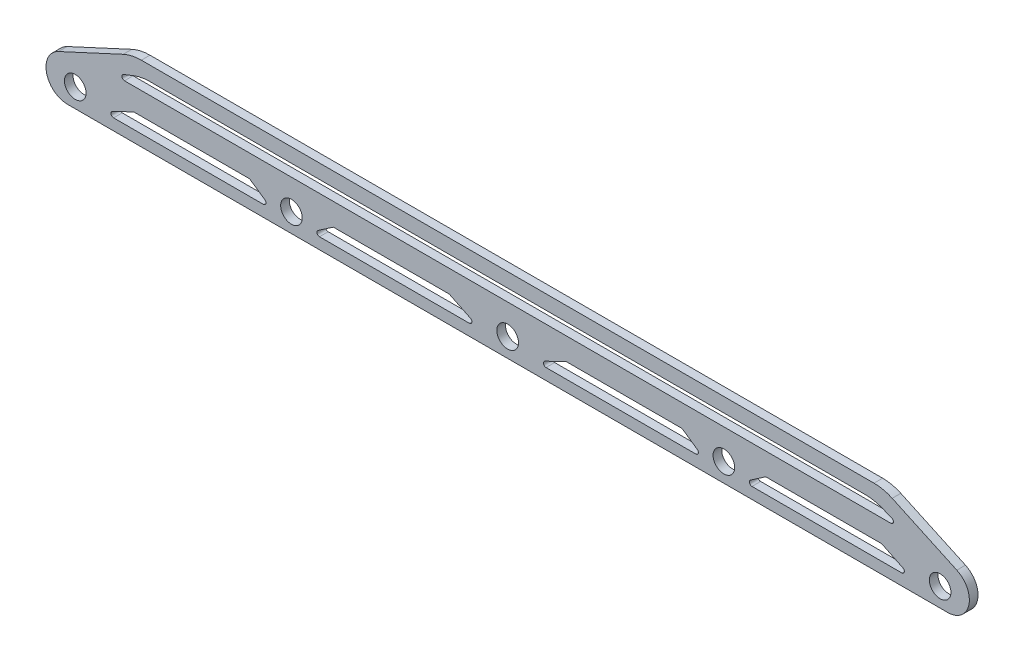
from build123d import *

# Parameters (mm, degrees)
SKETCH1_R           = 2.5
SKETCH1_R_2         = 2.506016037
BOSS_EXTRUDE1_DEPTH = 2


with BuildPart() as part:
    # Sketch1 → Boss-Extrude1 (new body)
    with BuildSketch(Plane.XY):
        with BuildLine():
            Line((84.714565194, 13), (-84.714565194, 13))
            ThreePointArc((-84.714565194, 13), (-86.865323204, 12.765973581), (-88.915414375, 12.074847997))
            Line((-88.915414375, 12.074847997), (-103.401698361, 5.368984247))
            Line((-103.401698361, 5.368984247), (-103.860380263, 5.156655237))
            ThreePointArc((-103.860380263, 5.156655237), (-106.642942464, -0.456147767), (-101.759955673, -4.380768762))
            Line((-101.759955673, -4.380768762), (101.759955673, -4.380768762))
            ThreePointArc((101.759955673, -4.380768762), (106.642942464, -0.456147767), (103.860380263, 5.156655237))
            Line((103.860380263, 5.156655237), (88.915414375, 12.074847997))
            ThreePointArc((88.915414375, 12.074847997), (86.865323204, 12.765973581), (84.714565194, 13))
        make_face()
        with Locations((-100, 0)):
            Circle(SKETCH1_R, mode=Mode.SUBTRACT)
        with BuildLine():
            Line((-59.681677735, 1.761321711), (-56.14514104, -0.666672148))
            ThreePointArc((-56.14514104, -0.666672148), (-55.911681313, -1.339099386), (-56.484737706, -1.761317581))
            Line((-56.484737706, -1.761317581), (-91.130638371, -1.761317581))
            ThreePointArc((-91.130638371, -1.761317581), (-91.71541475, -1.295617942), (-91.392423967, -0.621439537))
            Line((-91.392423967, -0.621439537), (-86.478477199, 1.761321711))
            Line((-86.478477199, 1.761321711), (-59.681677735, 1.761321711))
        make_face(mode=Mode.SUBTRACT)
        with Locations((-50, 0)):
            Circle(SKETCH1_R, mode=Mode.SUBTRACT)
        with BuildLine():
            Line((-13.521523964, 1.761321711), (-8.607577196, -0.621439537))
            ThreePointArc((-8.607577196, -0.621439537), (-8.284586412, -1.295617942), (-8.869362791, -1.761317581))
            Line((-8.869362791, -1.761317581), (-43.515263456, -1.761317581))
            ThreePointArc((-43.515263456, -1.761317581), (-44.08831985, -1.339099386), (-43.854860123, -0.666672148))
            Line((-43.854860123, -0.666672148), (-40.318323427, 1.761321711))
            Line((-40.318323427, 1.761321711), (-13.521523964, 1.761321711))
        make_face(mode=Mode.SUBTRACT)
        Circle(SKETCH1_R_2, mode=Mode.SUBTRACT)
        with BuildLine():
            Line((40.318323427, 1.761321711), (43.854860123, -0.666672148))
            ThreePointArc((43.854860123, -0.666672148), (44.08831985, -1.339099386), (43.515263456, -1.761317581))
            Line((43.515263456, -1.761317581), (8.869362791, -1.761317581))
            ThreePointArc((8.869362791, -1.761317581), (8.284586412, -1.295617942), (8.607577196, -0.621439537))
            Line((8.607577196, -0.621439537), (13.521523964, 1.761321711))
            Line((13.521523964, 1.761321711), (40.318323427, 1.761321711))
        make_face(mode=Mode.SUBTRACT)
        with Locations((50.000000581, 2.065e-06)):
            Circle(SKETCH1_R, mode=Mode.SUBTRACT)
        with BuildLine():
            Line((86.478477199, 1.761321711), (91.392423967, -0.621439537))
            ThreePointArc((91.392423967, -0.621439537), (91.71541475, -1.295617942), (91.130638371, -1.761317581))
            Line((91.130638371, -1.761317581), (56.484737706, -1.761317581))
            ThreePointArc((56.484737706, -1.761317581), (55.911681313, -1.339099386), (56.14514104, -0.666672148))
            Line((56.14514104, -0.666672148), (59.681677735, 1.761321711))
            Line((59.681677735, 1.761321711), (86.478477199, 1.761321711))
        make_face(mode=Mode.SUBTRACT)
        with Locations((100, 0)):
            Circle(SKETCH1_R, mode=Mode.SUBTRACT)
        with BuildLine():
            ThreePointArc((-86.478477199, 9.004514969), (-84.681411012, 9.523161606), (-82.81919634, 9.698083666))
            Line((-82.81919634, 9.698083666), (82.81919634, 9.698083666))
            ThreePointArc((82.81919634, 9.698083666), (84.681411012, 9.523161606), (86.478477199, 9.004514969))
            Line((86.478477199, 9.004514969), (88.830674001, 8.079633191))
            ThreePointArc((88.830674001, 8.079633191), (89.200621826, 7.409514432), (88.611117149, 6.921247313))
            Line((88.611117149, 6.921247313), (84.714565194, 6.921247313))
            Line((84.714565194, 6.921247313), (-84.714565194, 6.921247313))
            Line((-84.714565194, 6.921247313), (-88.611117149, 6.921247313))
            ThreePointArc((-88.611117149, 6.921247313), (-89.200621826, 7.409514432), (-88.830674001, 8.079633191))
            Line((-88.830674001, 8.079633191), (-86.478477199, 9.004514969))
        make_face(mode=Mode.SUBTRACT)
    extrude(amount=BOSS_EXTRUDE1_DEPTH)


solid = part.part
